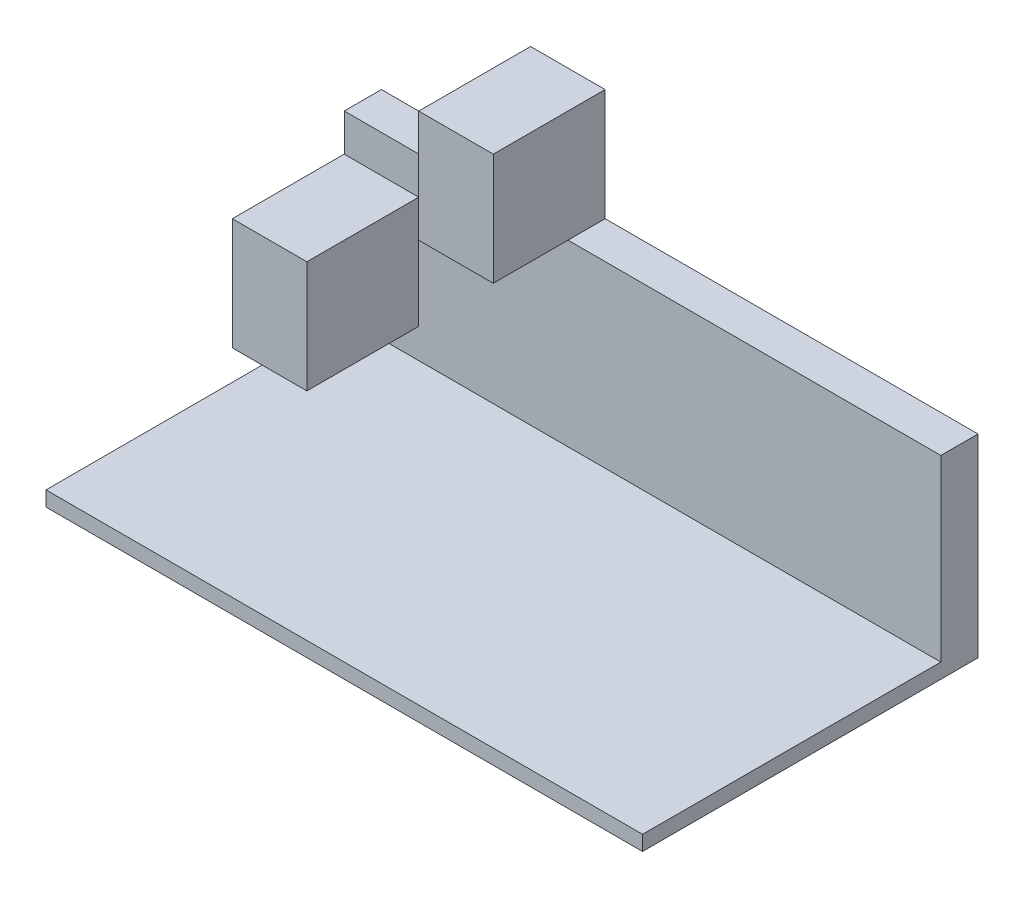
from build123d import *

# Parameters (mm, degrees)
SKETCH4_W           = 400
SKETCH4_H           = 24.926147639
BOSS_EXTRUDE1_DEPTH = 130
SKETCH5_W           = 400
SKETCH5_H           = 10
BOSS_EXTRUDE2_DEPTH = 200
SKETCH12_W          = 50
SKETCH12_H          = 75
BOSS_EXTRUDE3_DEPTH = 75


with BuildPart() as part:
    # Sketch4 → Boss-Extrude1 (new body)
    with BuildSketch(Plane.XZ.offset(300)):
        with Locations((0, 12.463073819)):
            Rectangle(SKETCH4_W, SKETCH4_H)
    extrude(amount=BOSS_EXTRUDE1_DEPTH)

    # Sketch5 → Boss-Extrude2 (add)
    with BuildSketch(Plane.XY.offset(24.926147639)):
        with Locations((0, -425)):
            Rectangle(SKETCH5_W, SKETCH5_H)
    extrude(amount=BOSS_EXTRUDE2_DEPTH)

    # Sketch12 → Boss-Extrude3 (add)
    with BuildSketch(Plane(origin=(0, -300, 0), x_dir=(1, 0, 0), z_dir=(0, 1, 0))):
        with Locations((-75, -162.5)):
            Rectangle(SKETCH12_W, SKETCH12_H)
        with Locations((-75, -37.5)):
            Rectangle(SKETCH12_W, SKETCH12_H)
    extrude(amount=BOSS_EXTRUDE3_DEPTH)


with BuildPart() as boss_extrude3_piece_1:
    # of the separate pieces the step leaves, piece 1, a body of its own (boss_extrude3_pieces)
    add(part.part.solids().sort_by_distance((-200, -300, 0))[0])


with BuildPart() as boss_extrude3_piece_2:
    # of the separate pieces the step leaves, piece 2, a body of its own (boss_extrude3_pieces)
    add(part.part.solids().sort_by_distance((-100, -300, 125))[0])


solid = Compound([boss_extrude3_piece_1.part, boss_extrude3_piece_2.part])
